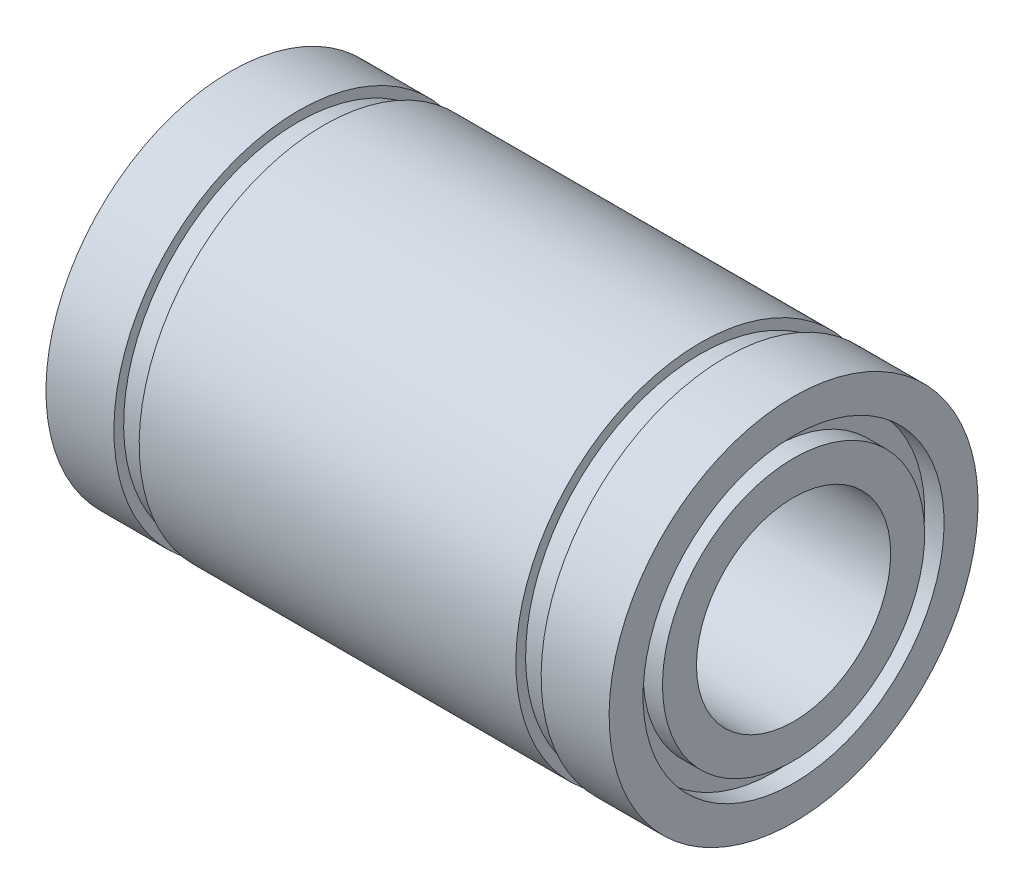
from build123d import *


with BuildPart() as part:
    # Esboço1 → Revolução1 (revolve)
    with BuildSketch(Plane.XY):
        Polygon((-14.5, 9.5), (-11, 9.5), (-11, 9), (-9.7, 9), (-9.7, 9.5), (9.7, 9.5), (9.7, 9), (11, 9), (11, 9.5), (14.5, 9.5), (14.5, 7.75), (13.5, 7.75), (13.5, 6.75), (14.5, 6.75), (14.5, 5), (-14.5, 5), (-14.5, 6.75), (-13.5, 6.75), (-13.5, 7.75), (-14.5, 7.75), align=None)
    revolve(axis=Axis((0, 0, 0), (-1, 0, 0)))


solid = part.part
